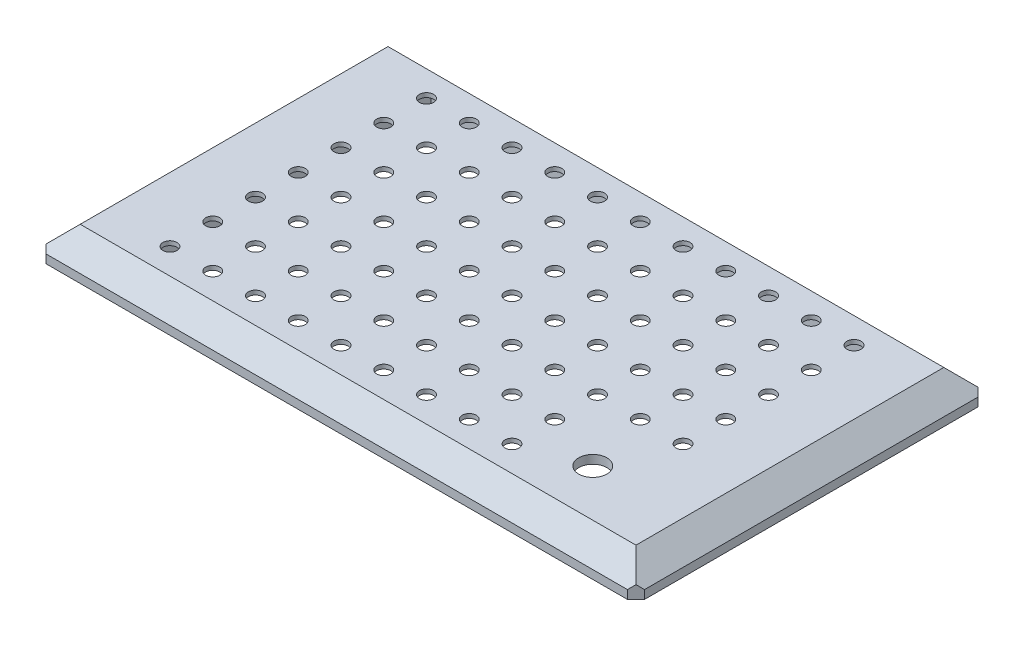
from build123d import *

# Parameters (mm, degrees)
SKETCH1_W           = 140
SKETCH1_H           = 82
BOSS_EXTRUDE1_DEPTH = 2
SKETCH3_W           = 130
SKETCH3_H           = 72
SKETCH2_W           = 140
SKETCH2_H           = 82
CHAMFER2_SIZE       = 2
SKETCH4_W           = 8
SKETCH4_H           = 10
BOSS_EXTRUDE2_DEPTH = 7
SKETCH5_R           = 2.05
CUT_EXTRUDE1_DEPTH  = 133.9000001
SKETCH6_W           = 107.8
SKETCH6_H           = 70
CUT_EXTRUDE2_DEPTH  = 5
SKETCH7_R           = 1.65
CUT_EXTRUDE3_DEPTH  = 3.0000001
SKETCH8_R           = 3.25
CUT_EXTRUDE4_DEPTH  = 1
SKETCH9_W           = 20
SKETCH9_H           = 20
BOSS_EXTRUDE3_DEPTH = 2
SKETCH10_R          = 3.3
CUT_EXTRUDE5_DEPTH  = 3.0000001


with BuildPart() as part:
    # Sketch1 → Boss-Extrude1 (new body)
    with BuildSketch(Plane(origin=(0, 0, 0), x_dir=(1, 0, 0), z_dir=(0, 1, 0))):
        Rectangle(SKETCH1_W, SKETCH1_H)
    extrude(amount=BOSS_EXTRUDE1_DEPTH)

    # Sketch3 → Loft1 section 0
    with BuildSketch(Plane(origin=(0, 7, 0), x_dir=(1, 0, 0), z_dir=(0, 1, 0))):
        Rectangle(SKETCH3_W, SKETCH3_H)
    # Sketch2 → Loft1 section 1
    with BuildSketch(Plane(origin=(0, 2, 0), x_dir=(1, 0, 0), z_dir=(0, 1, 0))):
        Rectangle(SKETCH2_W, SKETCH2_H)
    loft()

    # Chamfer2
    chamfer2_edges = [part.edges().sort_by_distance(p)[0] for p in [
        (70, 1, 41),
        (-70, 1, 41),
        (-70, 1, -41),
        (70, 1, -41),
    ]]
    chamfer(chamfer2_edges, length=CHAMFER2_SIZE)

    # Sketch4 → Boss-Extrude2 (add)
    with BuildSketch(Plane.XZ):
        with Locations((-58.9, 20)):
            Rectangle(SKETCH4_W, SKETCH4_H)
        with Locations((-58.9, -20)):
            Rectangle(SKETCH4_W, SKETCH4_H)
        with Locations((58.9, -20)):
            Rectangle(SKETCH4_W, SKETCH4_H)
        with Locations((58.9, 20)):
            Rectangle(SKETCH4_W, SKETCH4_H)
    extrude(amount=BOSS_EXTRUDE2_DEPTH)

    # Sketch5 → Cut-Extrude1 (cut, through all)
    with BuildSketch(Plane.ZY.offset(62.9)):
        with Locations((-20, -3.5)):
            Circle(SKETCH5_R)
        with Locations((20, -3.5)):
            Circle(SKETCH5_R)
    extrude(amount=-CUT_EXTRUDE1_DEPTH, mode=Mode.SUBTRACT)

    # Sketch6 → Cut-Extrude2 (cut)
    with BuildSketch(Plane.XZ):
        Rectangle(SKETCH6_W, SKETCH6_H)
    extrude(amount=-CUT_EXTRUDE2_DEPTH, mode=Mode.SUBTRACT)

    # Sketch7 → Cut-Extrude3 (cut, through all)
    with BuildSketch(Plane.XZ.offset(-5)):
        Circle(SKETCH7_R)
        with Locations((10, 0)):
            Circle(SKETCH7_R)
        with Locations((20, 0)):
            Circle(SKETCH7_R)
        with Locations((30, 0)):
            Circle(SKETCH7_R)
        with Locations((40, 0)):
            Circle(SKETCH7_R)
        with Locations((50, 0)):
            Circle(SKETCH7_R)
        with Locations((10, 10)):
            Circle(SKETCH7_R)
        with Locations((20, 10)):
            Circle(SKETCH7_R)
        with Locations((30, 10)):
            Circle(SKETCH7_R)
        with Locations((40, 10)):
            Circle(SKETCH7_R)
        with Locations((50, 10)):
            Circle(SKETCH7_R)
        with Locations((10, 20)):
            Circle(SKETCH7_R)
        with Locations((20, 20)):
            Circle(SKETCH7_R)
        with Locations((30, 20)):
            Circle(SKETCH7_R)
        with Locations((40, 20)):
            Circle(SKETCH7_R)
        with Locations((50, 20)):
            Circle(SKETCH7_R)
        with Locations((10, 30)):
            Circle(SKETCH7_R)
        with Locations((20, 30)):
            Circle(SKETCH7_R)
        with Locations((30, 30)):
            Circle(SKETCH7_R)
        with Locations((40, 30)):
            Circle(SKETCH7_R)
        with Locations((50, 30)):
            Circle(SKETCH7_R)
        with Locations((0, 10)):
            Circle(SKETCH7_R)
        with Locations((0, 20)):
            Circle(SKETCH7_R)
        with Locations((0, 30)):
            Circle(SKETCH7_R)
        with Locations((-50, 30)):
            Circle(SKETCH7_R)
        with Locations((-40, 30)):
            Circle(SKETCH7_R)
        with Locations((-30, 30)):
            Circle(SKETCH7_R)
        with Locations((-20, 30)):
            Circle(SKETCH7_R)
        with Locations((-10, 30)):
            Circle(SKETCH7_R)
        with Locations((-50, 20)):
            Circle(SKETCH7_R)
        with Locations((-40, 20)):
            Circle(SKETCH7_R)
        with Locations((-30, 20)):
            Circle(SKETCH7_R)
        with Locations((-20, 20)):
            Circle(SKETCH7_R)
        with Locations((-10, 20)):
            Circle(SKETCH7_R)
        with Locations((-50, 10)):
            Circle(SKETCH7_R)
        with Locations((-40, 10)):
            Circle(SKETCH7_R)
        with Locations((-30, 10)):
            Circle(SKETCH7_R)
        with Locations((-20, 10)):
            Circle(SKETCH7_R)
        with Locations((-10, 10)):
            Circle(SKETCH7_R)
        with Locations((-50, 0)):
            Circle(SKETCH7_R)
        with Locations((-40, 0)):
            Circle(SKETCH7_R)
        with Locations((-30, 0)):
            Circle(SKETCH7_R)
        with Locations((-20, 0)):
            Circle(SKETCH7_R)
        with Locations((-10, 0)):
            Circle(SKETCH7_R)
        with Locations((-10, -10)):
            Circle(SKETCH7_R)
        with Locations((-20, -10)):
            Circle(SKETCH7_R)
        with Locations((-30, -10)):
            Circle(SKETCH7_R)
        with Locations((-40, -10)):
            Circle(SKETCH7_R)
        with Locations((-50, -10)):
            Circle(SKETCH7_R)
        with Locations((-10, -20)):
            Circle(SKETCH7_R)
        with Locations((-20, -20)):
            Circle(SKETCH7_R)
        with Locations((-30, -20)):
            Circle(SKETCH7_R)
        with Locations((-40, -20)):
            Circle(SKETCH7_R)
        with Locations((-50, -20)):
            Circle(SKETCH7_R)
        with Locations((-10, -30)):
            Circle(SKETCH7_R)
        with Locations((-20, -30)):
            Circle(SKETCH7_R)
        with Locations((-30, -30)):
            Circle(SKETCH7_R)
        with Locations((-40, -30)):
            Circle(SKETCH7_R)
        with Locations((-50, -30)):
            Circle(SKETCH7_R)
        with Locations((0, -30)):
            Circle(SKETCH7_R)
        with Locations((0, -20)):
            Circle(SKETCH7_R)
        with Locations((0, -10)):
            Circle(SKETCH7_R)
        with Locations((50, -30)):
            Circle(SKETCH7_R)
        with Locations((40, -30)):
            Circle(SKETCH7_R)
        with Locations((30, -30)):
            Circle(SKETCH7_R)
        with Locations((20, -30)):
            Circle(SKETCH7_R)
        with Locations((10, -30)):
            Circle(SKETCH7_R)
        with Locations((50, -20)):
            Circle(SKETCH7_R)
        with Locations((40, -20)):
            Circle(SKETCH7_R)
        with Locations((30, -20)):
            Circle(SKETCH7_R)
        with Locations((20, -20)):
            Circle(SKETCH7_R)
        with Locations((10, -20)):
            Circle(SKETCH7_R)
        with Locations((50, -10)):
            Circle(SKETCH7_R)
        with Locations((40, -10)):
            Circle(SKETCH7_R)
        with Locations((30, -10)):
            Circle(SKETCH7_R)
        with Locations((20, -10)):
            Circle(SKETCH7_R)
        with Locations((10, -10)):
            Circle(SKETCH7_R)
    extrude(amount=-CUT_EXTRUDE3_DEPTH, mode=Mode.SUBTRACT)

    # Sketch8 → Cut-Extrude4 (cut)
    with BuildSketch(Plane.XZ.offset(-5)):
        Circle(SKETCH8_R)
        with Locations((10, 0)):
            Circle(SKETCH8_R)
        with Locations((20, 0)):
            Circle(SKETCH8_R)
        with Locations((30, 0)):
            Circle(SKETCH8_R)
        with Locations((40, 0)):
            Circle(SKETCH8_R)
        with Locations((50, 0)):
            Circle(SKETCH8_R)
        with Locations((10, 10)):
            Circle(SKETCH8_R)
        with Locations((20, 10)):
            Circle(SKETCH8_R)
        with Locations((30, 10)):
            Circle(SKETCH8_R)
        with Locations((40, 10)):
            Circle(SKETCH8_R)
        with Locations((50, 10)):
            Circle(SKETCH8_R)
        with Locations((10, 20)):
            Circle(SKETCH8_R)
        with Locations((20, 20)):
            Circle(SKETCH8_R)
        with Locations((30, 20)):
            Circle(SKETCH8_R)
        with Locations((40, 20)):
            Circle(SKETCH8_R)
        with Locations((50, 20)):
            Circle(SKETCH8_R)
        with Locations((10, 30)):
            Circle(SKETCH8_R)
        with Locations((20, 30)):
            Circle(SKETCH8_R)
        with Locations((30, 30)):
            Circle(SKETCH8_R)
        with Locations((40, 30)):
            Circle(SKETCH8_R)
        with Locations((50, 30)):
            Circle(SKETCH8_R)
        with Locations((0, 10)):
            Circle(SKETCH8_R)
        with Locations((0, 20)):
            Circle(SKETCH8_R)
        with Locations((0, 30)):
            Circle(SKETCH8_R)
        with Locations((0, -30)):
            Circle(SKETCH8_R)
        with Locations((0, -20)):
            Circle(SKETCH8_R)
        with Locations((0, -10)):
            Circle(SKETCH8_R)
        with Locations((50, -30)):
            Circle(SKETCH8_R)
        with Locations((40, -30)):
            Circle(SKETCH8_R)
        with Locations((30, -30)):
            Circle(SKETCH8_R)
        with Locations((20, -30)):
            Circle(SKETCH8_R)
        with Locations((10, -30)):
            Circle(SKETCH8_R)
        with Locations((50, -20)):
            Circle(SKETCH8_R)
        with Locations((40, -20)):
            Circle(SKETCH8_R)
        with Locations((30, -20)):
            Circle(SKETCH8_R)
        with Locations((20, -20)):
            Circle(SKETCH8_R)
        with Locations((10, -20)):
            Circle(SKETCH8_R)
        with Locations((50, -10)):
            Circle(SKETCH8_R)
        with Locations((40, -10)):
            Circle(SKETCH8_R)
        with Locations((30, -10)):
            Circle(SKETCH8_R)
        with Locations((20, -10)):
            Circle(SKETCH8_R)
        with Locations((10, -10)):
            Circle(SKETCH8_R)
        with Locations((-10, -10)):
            Circle(SKETCH8_R)
        with Locations((-20, -10)):
            Circle(SKETCH8_R)
        with Locations((-30, -10)):
            Circle(SKETCH8_R)
        with Locations((-40, -10)):
            Circle(SKETCH8_R)
        with Locations((-50, -10)):
            Circle(SKETCH8_R)
        with Locations((-10, -20)):
            Circle(SKETCH8_R)
        with Locations((-20, -20)):
            Circle(SKETCH8_R)
        with Locations((-30, -20)):
            Circle(SKETCH8_R)
        with Locations((-40, -20)):
            Circle(SKETCH8_R)
        with Locations((-50, -20)):
            Circle(SKETCH8_R)
        with Locations((-10, -30)):
            Circle(SKETCH8_R)
        with Locations((-20, -30)):
            Circle(SKETCH8_R)
        with Locations((-30, -30)):
            Circle(SKETCH8_R)
        with Locations((-40, -30)):
            Circle(SKETCH8_R)
        with Locations((-50, -30)):
            Circle(SKETCH8_R)
        with Locations((-50, 30)):
            Circle(SKETCH8_R)
        with Locations((-40, 30)):
            Circle(SKETCH8_R)
        with Locations((-30, 30)):
            Circle(SKETCH8_R)
        with Locations((-20, 30)):
            Circle(SKETCH8_R)
        with Locations((-10, 30)):
            Circle(SKETCH8_R)
        with Locations((-50, 20)):
            Circle(SKETCH8_R)
        with Locations((-40, 20)):
            Circle(SKETCH8_R)
        with Locations((-30, 20)):
            Circle(SKETCH8_R)
        with Locations((-20, 20)):
            Circle(SKETCH8_R)
        with Locations((-10, 20)):
            Circle(SKETCH8_R)
        with Locations((-50, 10)):
            Circle(SKETCH8_R)
        with Locations((-40, 10)):
            Circle(SKETCH8_R)
        with Locations((-30, 10)):
            Circle(SKETCH8_R)
        with Locations((-20, 10)):
            Circle(SKETCH8_R)
        with Locations((-10, 10)):
            Circle(SKETCH8_R)
        with Locations((-50, 0)):
            Circle(SKETCH8_R)
        with Locations((-40, 0)):
            Circle(SKETCH8_R)
        with Locations((-30, 0)):
            Circle(SKETCH8_R)
        with Locations((-20, 0)):
            Circle(SKETCH8_R)
        with Locations((-10, 0)):
            Circle(SKETCH8_R)
    extrude(amount=-CUT_EXTRUDE4_DEPTH, mode=Mode.SUBTRACT)

    # Sketch9 → Boss-Extrude3 (add)
    with BuildSketch(Plane(origin=(0, 7, 0), x_dir=(1, 0, 0), z_dir=(0, 1, 0))):
        with Locations((43.9, -25)):
            Rectangle(SKETCH9_W, SKETCH9_H)
    extrude(amount=-BOSS_EXTRUDE3_DEPTH)

    # Sketch10 → Cut-Extrude5 (cut, through all)
    with BuildSketch(Plane.XZ.offset(-5)):
        with Locations((43.9, 25)):
            Circle(SKETCH10_R)
    extrude(amount=-CUT_EXTRUDE5_DEPTH, mode=Mode.SUBTRACT)


solid = part.part
